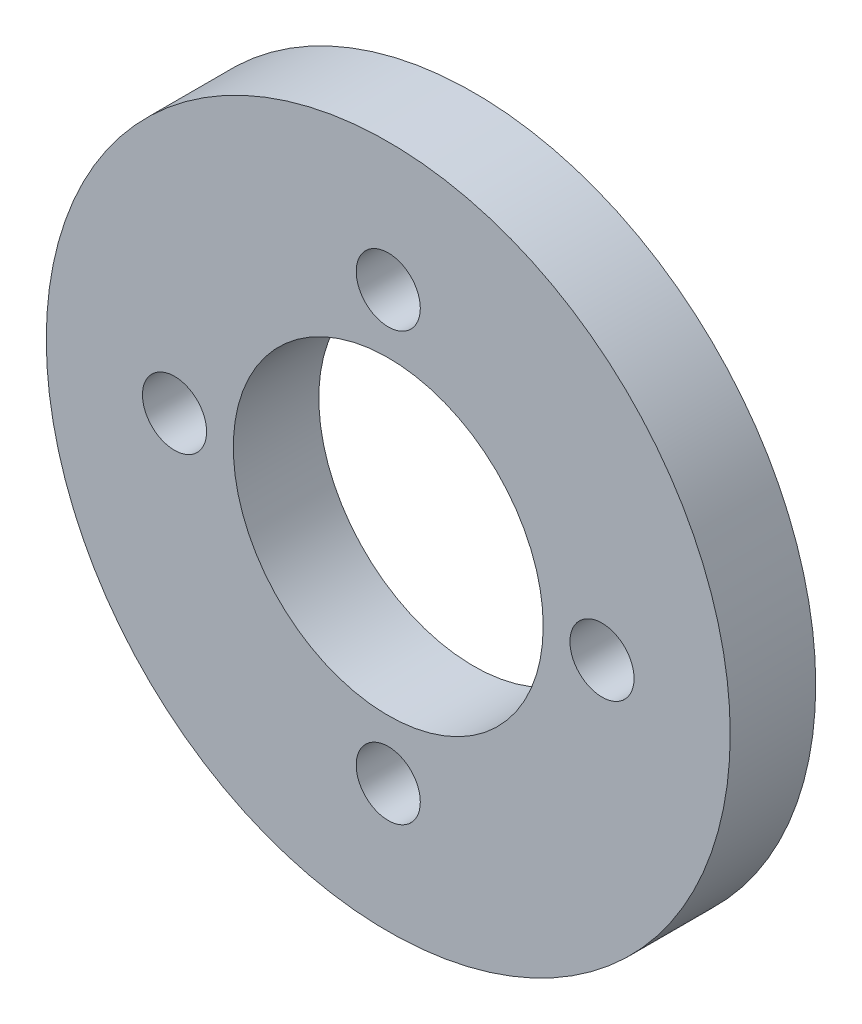
from build123d import *

# Parameters (mm, degrees)
SKETCH1_R           = 16
SKETCH1_R_2         = 7.25
SKETCH1_R_3         = 1.5
BOSS_EXTRUDE1_DEPTH = 4


with BuildPart() as part:
    # Sketch1 → Boss-Extrude1 (new body)
    with BuildSketch(Plane.XY):
        Circle(SKETCH1_R)
        Circle(SKETCH1_R_2, mode=Mode.SUBTRACT)
        with Locations((0, 10)):
            Circle(SKETCH1_R_3, mode=Mode.SUBTRACT)
        with Locations((10, 0)):
            Circle(SKETCH1_R_3, mode=Mode.SUBTRACT)
        with Locations((0, -10)):
            Circle(SKETCH1_R_3, mode=Mode.SUBTRACT)
        with Locations((-10, 0)):
            Circle(SKETCH1_R_3, mode=Mode.SUBTRACT)
    extrude(amount=BOSS_EXTRUDE1_DEPTH)


solid = part.part
